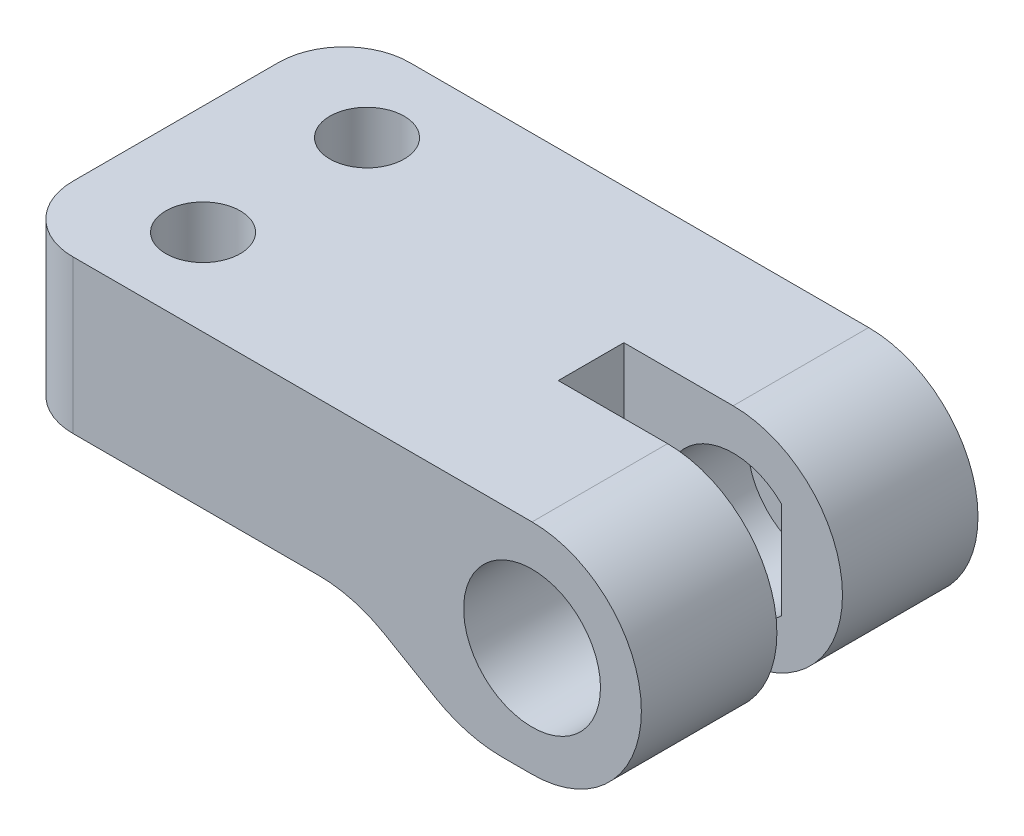
from build123d import *

# Parameters (mm, degrees)
DODANIE_WYCI_GNI_CIE1_DEPTH      = 15.4
SZKIC2_R                         = 3.13
WYTNIJ_WYCI_GNI_CIE1_DEPTH       = 13
WYTNIJ_WYCI_GNI_CIE13_DEPTH      = 7.62
WYTNIJ_WYCI_GNI_CIE13_DEPTH_BACK = 9.78
DODANIE_WYCI_GNI_CIE2_START      = -17.88
DODANIE_WYCI_GNI_CIE2_DEPTH      = 13.5
SZKIC18_W                        = 10
SZKIC18_H                        = 3
WYTNIJ_WYCI_GNI_CIE14_DEPTH      = 11
ZAOKR_GLENIE2_R                  = 3
ZAOKR_GLENIE3_R                  = 6
WYTNIJ_WYCI_GNI_CIE15_DEPTH      = 3
ZAOKR_GLENIE5_R                  = 2
SZKIC20_R                        = 1.7
WYTNIJ_WYCI_GNI_CIE16_DEPTH      = 11
WYTNIJ_WYCI_GNI_CIE17_DEPTH      = 3


with BuildPart() as part:
    # Szkic1 → Dodanie-wyciągnięcie1 (new body)
    with BuildSketch(Plane.XY):
        with BuildLine():
            Line((0, 0), (-24, 0))
            Line((-24, 0), (-24, 10))
            Line((-24, 10), (0, 10))
            ThreePointArc((0, 10), (5, 5), (0, 0))
        make_face()
    extrude(amount=DODANIE_WYCI_GNI_CIE1_DEPTH)

    # Szkic2 → Wytnij-wyciągnięcie1 (cut)
    with BuildSketch(Plane.XY.offset(15.4)):
        with Locations((0, 5)):
            Circle(SZKIC2_R)
    extrude(amount=-WYTNIJ_WYCI_GNI_CIE1_DEPTH, mode=Mode.SUBTRACT)

    # Szkic16 → Wytnij-wyciągnięcie13 (cut, two sides)
    with BuildSketch(Plane(origin=(0, 0, 6.62), x_dir=(-1, 0, 0), z_dir=(0, 0, -1))) as wytnij_wyci_gni_cie13_sk:
        Polygon((31, 0), (31, 3), (8.153065534, 3), (3, 0), align=None)
    extrude(amount=WYTNIJ_WYCI_GNI_CIE13_DEPTH, mode=Mode.SUBTRACT)
    extrude(wytnij_wyci_gni_cie13_sk.sketch, amount=-WYTNIJ_WYCI_GNI_CIE13_DEPTH_BACK, mode=Mode.SUBTRACT)

    # Szkic10 → Dodanie-wyciągnięcie2 (add)
    with BuildSketch(Plane.XY.offset(17.88).offset(DODANIE_WYCI_GNI_CIE2_START)):
        with BuildLine():
            Line((2.2, 7.226409666), (2.2, 2.773590334))
            ThreePointArc((2.2, 2.773590334), (3.13, 5), (2.2, 7.226409666))
        make_face()
    extrude(amount=DODANIE_WYCI_GNI_CIE2_DEPTH)

    # Szkic18 → Wytnij-wyciągnięcie14 (cut, through all)
    with BuildSketch(Plane(origin=(0, 10, 0), x_dir=(1, 0, 0), z_dir=(0, 1, 0))):
        with Locations((0, -7.7)):
            Rectangle(SZKIC18_W, SZKIC18_H)
    extrude(amount=-WYTNIJ_WYCI_GNI_CIE14_DEPTH, mode=Mode.SUBTRACT)

    # Zaokrąglenie2
    zaokr_glenie2_edges = [part.edges().sort_by_distance(p)[0] for p in [
        (-24, 6.5, 0),
        (-24, 6.5, 15.4),
    ]]
    fillet(zaokr_glenie2_edges, radius=ZAOKR_GLENIE2_R)

    # Zaokrąglenie3
    zaokr_glenie3_edges = [part.edges().sort_by_distance(p)[0] for p in [
        (-3, 0, 12.3),
        (-8.153065534, 3, 7.7),
        (-3, 0, 3.1),
    ]]
    fillet(zaokr_glenie3_edges, radius=ZAOKR_GLENIE3_R)

    # Szkic19 → Wytnij-wyciągnięcie15 (cut)
    with BuildSketch(Plane(origin=(0, 0, 9.2), x_dir=(-1, 0, 0), z_dir=(0, 0, -1))):
        Polygon((3.986195456, 3), (13.986195456, 3), (0.751466107, -7.194094716), align=None)
    extrude(amount=WYTNIJ_WYCI_GNI_CIE15_DEPTH, mode=Mode.SUBTRACT)

    # Zaokrąglenie5
    zaokr_glenie5_edges = [part.edges().sort_by_distance(p)[0] for p in [
        (-5, 3, 7.7),
    ]]
    fillet(zaokr_glenie5_edges, radius=ZAOKR_GLENIE5_R)

    # Szkic20 → Wytnij-wyciągnięcie16 (cut, through all)
    with BuildSketch(Plane(origin=(0, 10, 0), x_dir=(1, 0, 0), z_dir=(0, 1, 0))):
        with Locations((-19, -3.95)):
            Circle(SZKIC20_R)
        with Locations((-19, -11.45)):
            Circle(SZKIC20_R)
    extrude(amount=-WYTNIJ_WYCI_GNI_CIE16_DEPTH, mode=Mode.SUBTRACT)

    # Szkic21 → Wytnij-wyciągnięcie17 (cut)
    with BuildSketch(Plane(origin=(0, 3, 0), x_dir=(-1, 0, 0), z_dir=(0, -1, 0))):
        Polygon((15.709103466, -3.95), (17.354551733, -6.8), (20.645448267, -6.8), (22.290896534, -3.95), (20.645448267, -1.1), (17.354551733, -1.1), align=None)
        Polygon((15.709103466, -11.45), (17.354551733, -14.3), (20.645448267, -14.3), (22.290896534, -11.45), (20.645448267, -8.6), (17.354551733, -8.6), align=None)
    extrude(amount=-WYTNIJ_WYCI_GNI_CIE17_DEPTH, mode=Mode.SUBTRACT)


solid = part.part
